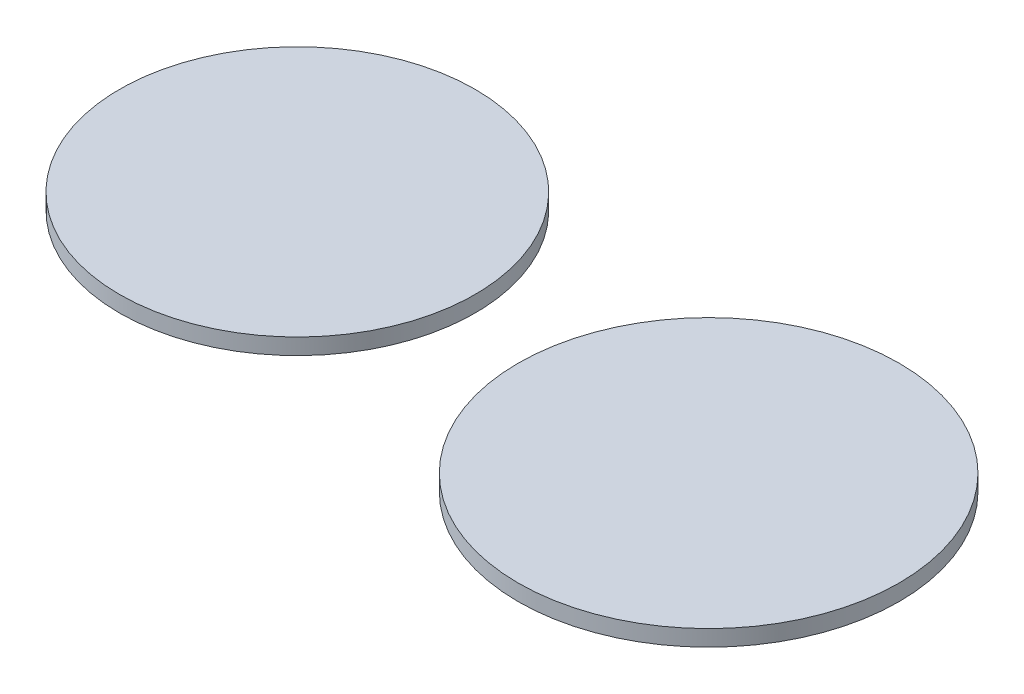
from build123d import *

# Parameters (mm, degrees)
SKETCH1_R             = 30
BOSS_EXTRUDE1_DEPTH   = 2.54
SKETCH1_R_2           = 28
BOSS_EXTRUDE1_2_DEPTH = 2.54


with BuildPart() as part:
    # Sketch1 → Boss-Extrude1 (new body)
    with BuildSketch(Plane(origin=(0, 0, 0), x_dir=(1, 0, 0), z_dir=(0, 1, 0))):
        Circle(SKETCH1_R)
    extrude(amount=BOSS_EXTRUDE1_DEPTH)


with BuildPart() as body_2:
    # Sketch1 → Boss-Extrude1 2 (new body)
    with BuildSketch(Plane(origin=(0, 0, 0), x_dir=(1, 0, 0), z_dir=(0, 1, 0))):
        with Locations((-70.755335685, 5.96676125)):
            Circle(SKETCH1_R_2)
    extrude(amount=BOSS_EXTRUDE1_2_DEPTH)


solid = Compound([part.part, body_2.part])
